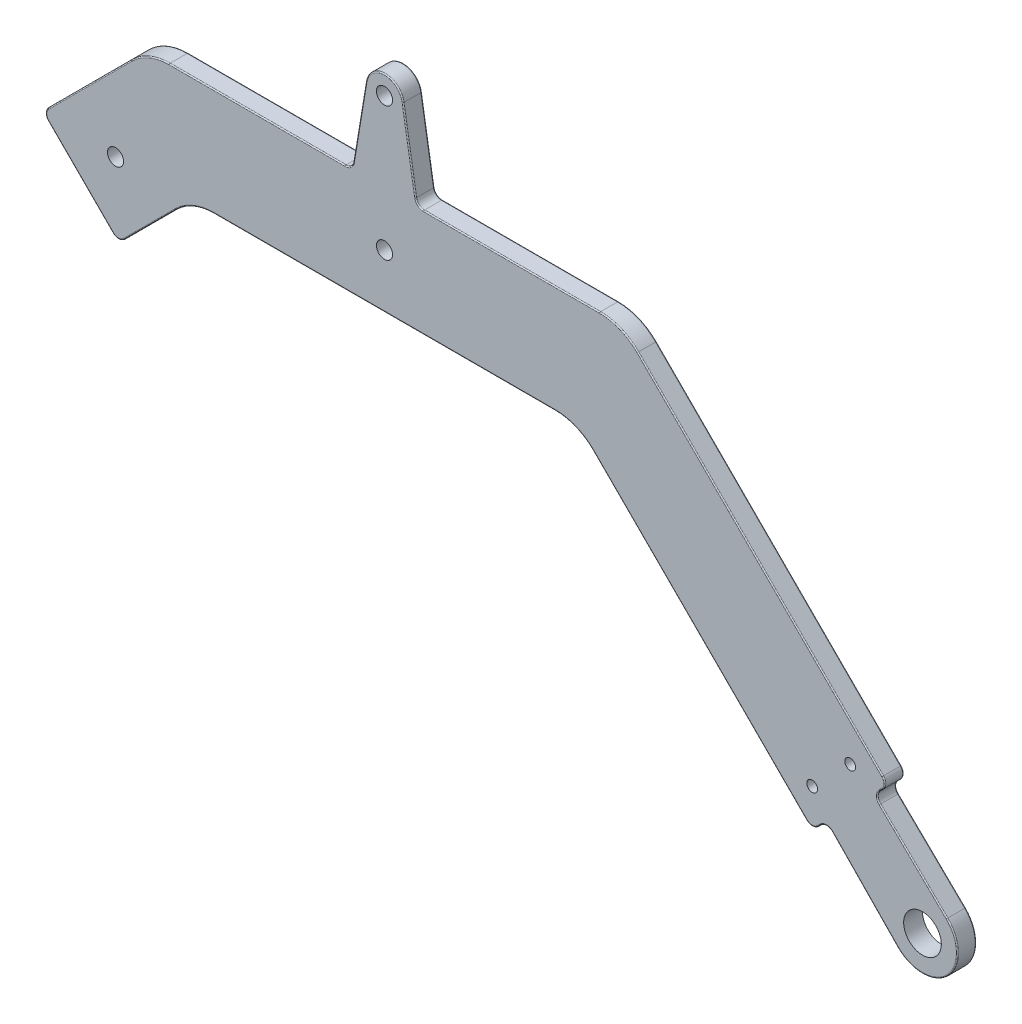
from build123d import *

# Parameters (mm, degrees)
SKETCH5_R           = 3.5
SKETCH5_R_2         = 1.5
SKETCH5_R_3         = 1
BOSS_EXTRUDE2_DEPTH = 3.5
FILLET1_R           = 10
FILLET2_R           = 1.5
FILLET3_R           = 0.2


with BuildPart() as part:
    # Sketch5 → Boss-Extrude2 (new body)
    with BuildSketch(Plane.XY):
        with BuildLine():
            Line((90.980851591, 17.850909276), (104.533955357, 4.657601188))
            ThreePointArc((104.533955357, 4.657601188), (104.596194078, -4.596194078), (95.342398812, -4.533955357))
            Line((95.342398812, -4.533955357), (82.149090724, 9.019148409))
            Line((82.149090724, 9.019148409), (79.493903346, 6.363961031))
            Line((79.493903346, 6.363961031), (35.857864376, 50))
            Line((35.857864376, 50), (-35.857864376, 50))
            Line((-35.857864376, 50), (-49.445436483, 36.412427894))
            Line((-49.445436483, 36.412427894), (-63.587572106, 50.554563517))
            Line((-63.587572106, 50.554563517), (-44.142135624, 70))
            Line((-44.142135624, 70), (-6, 70))
            Line((-6, 70), (-3.453220204, 85.420324662))
            ThreePointArc((-3.453220204, 85.420324662), (0, 88.35), (3.453220204, 85.420324662))
            Line((3.453220204, 85.420324662), (6, 70))
            Line((6, 70), (44.142135624, 70))
            Line((44.142135624, 70), (93.636038969, 20.506096654))
            Line((93.636038969, 20.506096654), (90.980851591, 17.850909276))
        make_face()
        with Locations((100, 0)):
            Circle(SKETCH5_R, mode=Mode.SUBTRACT)
        with Locations((0, 84.85)):
            Circle(SKETCH5_R_2, mode=Mode.SUBTRACT)
        with Locations((0, 60)):
            Circle(SKETCH5_R_2, mode=Mode.SUBTRACT)
        with Locations((86.564971157, 20.506096654)):
            Circle(SKETCH5_R_3, mode=Mode.SUBTRACT)
        with Locations((79.493903346, 13.435028843)):
            Circle(SKETCH5_R_3, mode=Mode.SUBTRACT)
        with Locations((-50, 50)):
            Circle(SKETCH5_R_2, mode=Mode.SUBTRACT)
    extrude(amount=BOSS_EXTRUDE2_DEPTH)

    # Fillet1
    fillet1_edges = [part.edges().sort_by_distance(p)[0] for p in [
        (44.142135624, 70, 1.75),
        (35.857864376, 50, 1.75),
        (-35.857864376, 50, 1.75),
        (-44.142135624, 70, 1.75),
    ]]
    fillet(fillet1_edges, radius=FILLET1_R)

    # Fillet2
    fillet2_edges = [part.edges().sort_by_distance(p)[0] for p in [
        (6, 70, 1.75),
        (93.636038969, 20.506096654, 1.75),
        (90.980851591, 17.850909276, 1.75),
        (82.149090724, 9.019148409, 1.75),
        (79.493903346, 6.363961031, 1.75),
        (-49.445436483, 36.412427894, 1.75),
        (-63.587572106, 50.554563517, 1.75),
        (-6, 70, 1.75),
    ]]
    fillet(fillet2_edges, radius=FILLET2_R)

    # Fillet3
    fillet3_edges = [part.edges().sort_by_distance(p)[0] for p in [
        (98.302096991, 10.724021751, 0),
        (89.275978249, 1.697903009, 0),
        (80.814314994, 7.684372679, 0),
        (-56.516504294, 43.483495706, 0),
        (-23.636292033, 70, 0),
        (-4.622926377, 78.337949903, 0),
        (4.622926377, 78.337949903, 0),
        (79.493903346, 6.985281374, 0),
        (93.014718626, 20.506096654, 0),
        (-62.966251763, 50.554563517, 0),
        (-49.445436483, 37.033748237, 0),
        (-56.516504294, 43.483495706, 3.5),
        (69.823223305, 44.318912319, 3.5),
        (4.622926377, 78.337949903, 3.5),
        (-4.622926377, 78.337949903, 3.5),
        (-23.636292033, 70, 3.5),
        (80.814314994, 7.684372679, 3.5),
        (89.275978249, 1.697903009, 3.5),
        (98.302096991, 10.724021751, 3.5),
        (92.315627321, 19.185685006, 3.5),
        (79.493903346, 6.985281374, 3.5),
        (93.014718626, 20.506096654, 3.5),
        (-62.966251763, 50.554563517, 3.5),
        (-49.445436483, 37.033748237, 3.5),
        (6.302181387, 70.356182427, 0),
        (6.302181387, 70.356182427, 3.5),
        (-6.302181387, 70.356182427, 0),
        (-6.302181387, 70.356182427, 3.5),
        (91.616569941, 17.855184959, 0),
        (91.616569941, 17.855184959, 3.5),
        (82.144815041, 8.383430059, 0),
        (82.144815041, 8.383430059, 3.5),
        (104.596194078, -4.596194078, 0),
        (0, 88.35, 0),
        (0, 88.35, 3.5),
        (23.636292033, 70, 0),
        (23.636292033, 70, 3.5),
        (58.610019869, 27.247844507, 0),
        (0, 50, 0),
        (-54.798989873, 59.343145751, 0),
        (-43.826834324, 69.238795325, 0),
        (43.826834324, 69.238795325, 0),
        (-54.798989873, 59.343145751, 3.5),
        (0, 50, 3.5),
        (58.610019869, 27.247844507, 3.5),
        (-43.826834324, 69.238795325, 3.5),
        (43.826834324, 69.238795325, 3.5),
        (35.542563076, 49.238795325, 0),
        (35.542563076, 49.238795325, 3.5),
        (-35.542563076, 49.238795325, 0),
        (-35.542563076, 49.238795325, 3.5),
        (104.596194078, -4.596194078, 3.5),
        (-43.585786438, 42.272077939, 0),
        (-43.585786438, 42.272077939, 3.5),
        (69.823223305, 44.318912319, 0),
        (92.315627321, 19.185685006, 0),
    ]]
    fillet(fillet3_edges, radius=FILLET3_R)


solid = part.part
